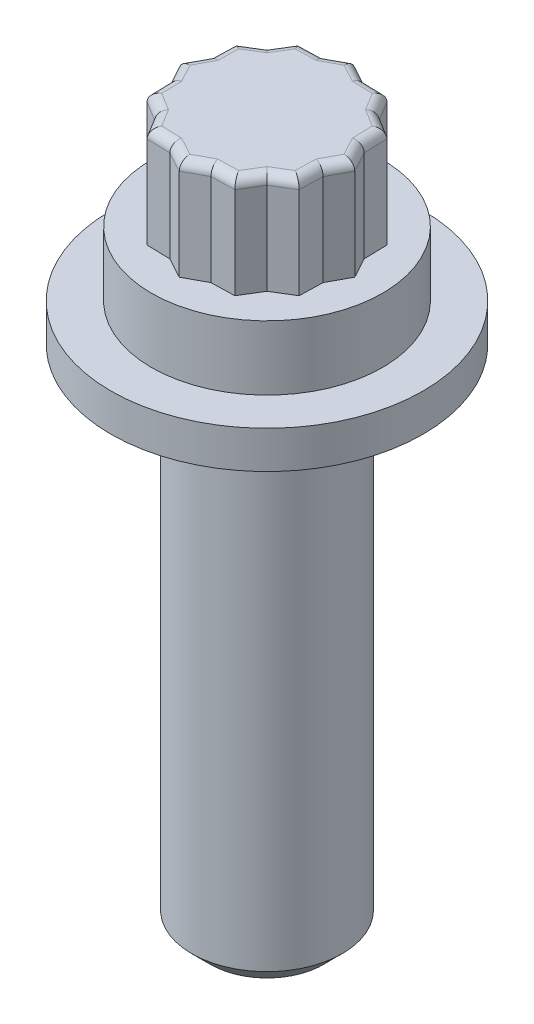
from build123d import *

# Parameters (mm, degrees)
SKETCH8_R           = 6.35
SKETCH8_R_2         = 3.429
WASHER_DEPTH        = 1.524
SKETCH9_R           = 3.0607
BOSS_EXTRUDE4_DEPTH = 22.225
SKETCH10_R          = 4.699
BOSS_EXTRUDE5_DEPTH = 6.731
SKETCH11_R          = 4.699
CUT_EXTRUDE2_DEPTH  = 4.1148
FILLET5_R           = 0.381
CHAMFER1_SIZE       = 0.762


with BuildPart() as part:
    # Sketch8 → Washer (new body)
    with BuildSketch(Plane(origin=(0, 0, 0), x_dir=(1, 0, 0), z_dir=(0, 1, 0))):
        Circle(SKETCH8_R)
        Circle(SKETCH8_R_2, mode=Mode.SUBTRACT)
    extrude(amount=WASHER_DEPTH)


with BuildPart() as body_2:
    # Sketch9 → Boss-Extrude4 (new body)
    with BuildSketch(Plane(origin=(0, 1.524, 0), x_dir=(1, 0, 0), z_dir=(0, 1, 0))):
        Circle(SKETCH9_R)
    extrude(amount=-BOSS_EXTRUDE4_DEPTH)


with BuildPart() as body_3:
    # Sketch10 → Boss-Extrude5 (new body)
    with BuildSketch(Plane(origin=(0, 1.524, 0), x_dir=(1, 0, 0), z_dir=(0, 1, 0))):
        Circle(SKETCH10_R)
    extrude(amount=BOSS_EXTRUDE5_DEPTH)

    # Sketch11 → Cut-Extrude2 (cut)
    with BuildSketch(Plane(origin=(0, 8.255, 0), x_dir=(1, 0, 0), z_dir=(0, 1, 0))):
        Circle(SKETCH11_R)
        Polygon((0, 3.5687), (-0.834898476, 3.11588353), (-1.78435, 3.090584858), (-2.280985055, 2.280985055), (-3.090584858, 1.78435), (-3.11588353, 0.834898476), (-3.5687, 0), (-3.11588353, -0.834898476), (-3.090584858, -1.78435), (-2.280985055, -2.280985055), (-1.78435, -3.090584858), (-0.834898476, -3.11588353), (0, -3.5687), (0.834898476, -3.11588353), (1.78435, -3.090584858), (2.280985055, -2.280985055), (3.090584858, -1.78435), (3.11588353, -0.834898476), (3.5687, 0), (3.11588353, 0.834898476), (3.090584858, 1.78435), (2.280985055, 2.280985055), (1.78435, 3.090584858), (0.834898476, 3.11588353), align=None, mode=Mode.SUBTRACT)
    extrude(amount=-CUT_EXTRUDE2_DEPTH, mode=Mode.SUBTRACT)


with BuildPart() as body_2_1:
    add(body_2.part)

    # Combine1: union body 3
    add(body_3.part)

    # Fillet5
    fillet5_edges = [body_2_1.edges().sort_by_distance(p)[0] for p in [
        (-0.417449238, 8.255, -3.342291765),
        (-1.309624238, 8.255, -3.103234194),
        (-2.032667527, 8.255, -2.685784957),
        (-2.685784957, 8.255, -2.032667527),
        (-3.103234194, 8.255, -1.309624238),
        (-3.342291765, 8.255, -0.417449238),
        (-3.342291765, 8.255, 0.417449238),
        (-3.103234194, 8.255, 1.309624238),
        (-2.685784957, 8.255, 2.032667527),
        (-2.032667527, 8.255, 2.685784957),
        (-1.309624238, 8.255, 3.103234194),
        (-0.417449238, 8.255, 3.342291765),
        (0.417449238, 8.255, 3.342291765),
        (1.309624238, 8.255, 3.103234194),
        (2.032667527, 8.255, 2.685784957),
        (2.685784957, 8.255, 2.032667527),
        (3.103234194, 8.255, 1.309624238),
        (3.342291765, 8.255, 0.417449238),
        (3.342291765, 8.255, -0.417449238),
        (3.103234194, 8.255, -1.309624238),
        (2.685784957, 8.255, -2.032667527),
        (2.032667527, 8.255, -2.685784957),
        (1.309624238, 8.255, -3.103234194),
        (0.417449238, 8.255, -3.342291765),
    ]]
    fillet(fillet5_edges, radius=FILLET5_R)

    # Chamfer1
    chamfer1_edges = [body_2_1.edges().sort_by_distance(p)[0] for p in [
        (-3.0607, -20.701, 0),
    ]]
    chamfer(chamfer1_edges, length=CHAMFER1_SIZE)


solid = Compound([part.part, body_2_1.part])
